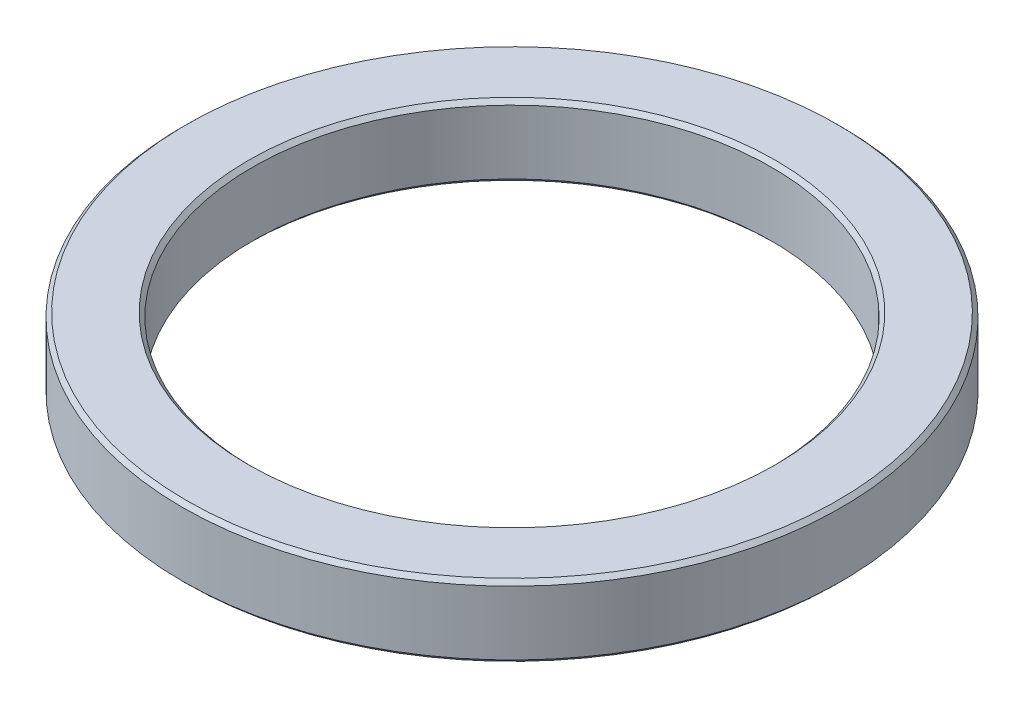
from build123d import *

# Parameters (mm, degrees)
SKETCH_1_R      = 82.5
SKETCH_1_R_2    = 65
EXTRUDE_1_DEPTH = 18
CHAMFER_1_SIZE  = 1


with BuildPart() as part:
    # 草图1 → 凸台-拉伸1 (new body)
    with BuildSketch(Plane(origin=(0, 0, 0), x_dir=(1, 0, 0), z_dir=(0, 1, 0))):
        Circle(SKETCH_1_R)
        Circle(SKETCH_1_R_2, mode=Mode.SUBTRACT)
    extrude(amount=EXTRUDE_1_DEPTH)

    # 倒角1
    chamfer_1_edges = [part.edges().sort_by_distance(p)[0] for p in [
        (-82.5, 0, 0),
        (-82.5, 18, 0),
        (-65, 0, 0),
        (-65, 18, 0),
    ]]
    chamfer(chamfer_1_edges, length=CHAMFER_1_SIZE)


solid = part.part
